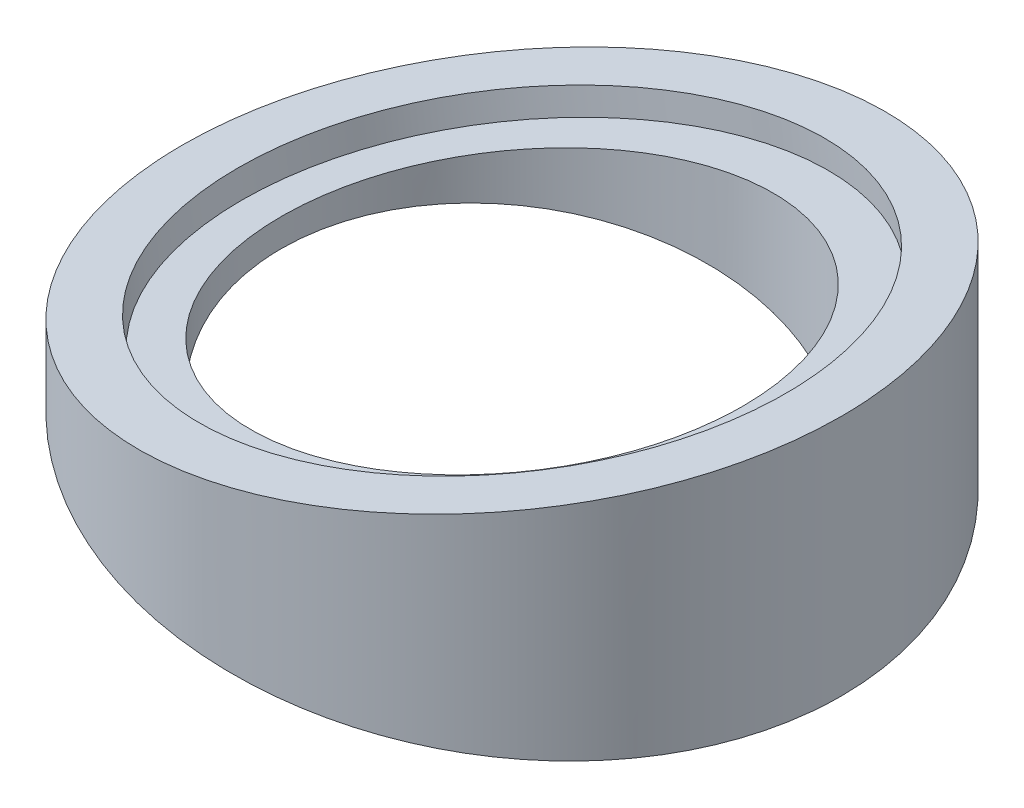
from build123d import *

# Parameters (mm, degrees)
SKETCH_1_R          = 25
EXTRUDE_1_DEPTH     = 40
SKETCH_2_R          = 17.5
CUT_EXTRUDE_1_DEPTH = 72
CUT_EXTRUDE_2_DEPTH = 38.5
SKETCH_6_R          = 21
CUT_EXTRUDE_6_DEPTH = 2
SKETCH_7_R          = 21
CUT_EXTRUDE_7_DEPTH = 2


with BuildPart() as part:
    # 草图1 → 凸台-拉伸1 (new body)
    with BuildSketch(Plane(origin=(0, 0, 0), x_dir=(1, 0, 0), z_dir=(0, 1, 0))):
        with Locations(Location((0, 0, 0), (0, 0, 270))):
            Circle(SKETCH_1_R)
    extrude(amount=EXTRUDE_1_DEPTH)

    # 草图2 → 切除-拉伸1 (cut)
    with BuildSketch(Plane(origin=(0, 40, 0), x_dir=(1, 0, 0), z_dir=(0, 1, 0))):
        with Locations(Location((0, 0, 0), (0, 0, 270))):
            Circle(SKETCH_2_R)
    extrude(amount=-CUT_EXTRUDE_1_DEPTH, mode=Mode.SUBTRACT)

    # 草图3 → 切除-拉伸2 (cut, symmetric)
    with BuildSketch(Plane.XY):
        Polygon((-25, 22), (25, 29.188898505), (25, 44.224311684), (-25, 43.752919673), align=None)
        Polygon((25, -4.224311684), (-25, -3.752919673), (-25, 18), (25, 10.811101495), align=None)
    extrude(amount=CUT_EXTRUDE_2_DEPTH, both=True, mode=Mode.SUBTRACT)

    # 草图6 → 切除-拉伸6 (cut)
    with BuildSketch(Plane(origin=(-3.605387021, 25.076074025, 0), x_dir=(0.9898214870420192, 0.14231452417067597, 0), z_dir=(-0.14231452417067594, 0.9898214870420191, 0))):
        with Locations(Location((3.642461867, 0, 0), (0, 0, 180))):
            Circle(SKETCH_6_R)
    extrude(amount=-CUT_EXTRUDE_6_DEPTH, mode=Mode.SUBTRACT)

    # 草图7 → 切除-拉伸7 (cut)
    with BuildSketch(Plane(origin=(2.029251936, 14.113789023, 0), x_dir=(0.9898214870420192, -0.14231452417067597, 0), z_dir=(-0.14231452417067594, -0.9898214870420191, 0))):
        with Locations((-2.0501191, 0)):
            Circle(SKETCH_7_R)
    extrude(amount=-CUT_EXTRUDE_7_DEPTH, mode=Mode.SUBTRACT)


solid = part.part
